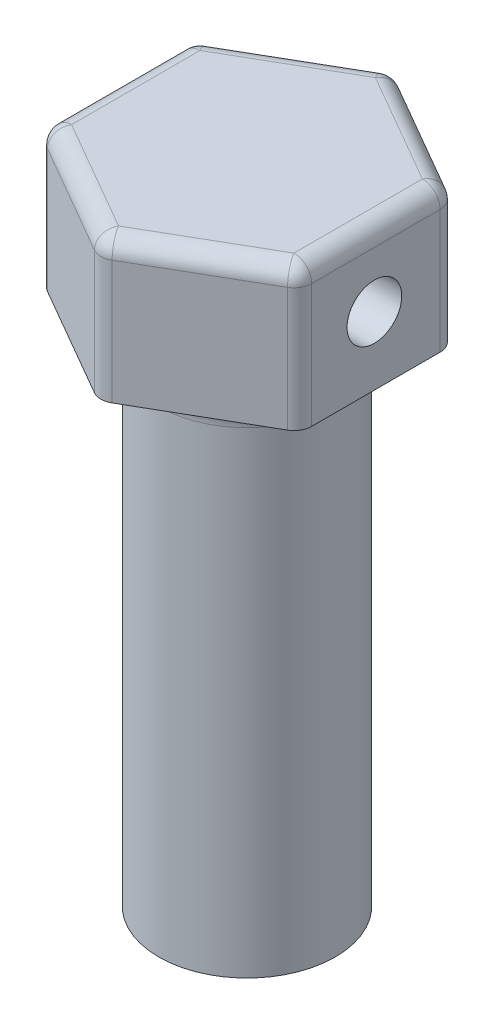
from build123d import *

# Parameters (mm, degrees)
BOSS_EXTRUDE1_DEPTH = 8
SKETCH2_R           = 5
BOSS_EXTRUDE2_DEPTH = 29
FILLET1_R           = 2
SKETCH3_R           = 1.55
CUT_EXTRUDE1_DEPTH  = 15.6
FILLET2_R           = 1
SKETCH5_R           = 2.0875
CUT_EXTRUDE3_DEPTH  = 3
CUT_EXTRUDE4_REACH  = 10
SKETCH6_R           = 1.25
SKETCH7_R           = 0.5
CUT_EXTRUDE5_DEPTH  = 0.5


with BuildPart() as part:
    # Sketch1 → Boss-Extrude1 (new body)
    with BuildSketch(Plane(origin=(0, 0, 0), x_dir=(1, 0, 0), z_dir=(0, 1, 0))):
        Polygon((7.3, -4.214656965), (7.3, 4.214656965), (0, 8.42931393), (-7.3, 4.214656965), (-7.3, -4.214656965), (0, -8.42931393), align=None)
    extrude(amount=BOSS_EXTRUDE1_DEPTH)

    # Sketch2 → Boss-Extrude2 (add)
    with BuildSketch(Plane.XZ):
        Circle(SKETCH2_R)
        with BuildLine():
            Line((-1.5, 1.451776928), (-1.5, -1.451776928))
            ThreePointArc((-1.5, -1.451776928), (2.0875, 0), (-1.5, 1.451776928))
        make_face(mode=Mode.SUBTRACT)
    extrude(amount=BOSS_EXTRUDE2_DEPTH)

    # Fillet1
    fillet1_edges = [part.edges().sort_by_distance(p)[0] for p in [
        (-5, 0, 0),
    ]]
    fillet(fillet1_edges, radius=FILLET1_R)

    # Sketch3 → Cut-Extrude1 (cut, through all)
    with BuildSketch(Plane(origin=(7.3, 0, 0), x_dir=(0, 0, -1), z_dir=(1, 0, 0))):
        with Locations((-0.085343035, 3.85)):
            Circle(SKETCH3_R)
    extrude(amount=-CUT_EXTRUDE1_DEPTH, mode=Mode.SUBTRACT)

    # Fillet2
    fillet2_edges = [part.edges().sort_by_distance(p)[0] for p in [
        (0, 4, 8.42931393),
        (-7.3, 4, 4.214656965),
        (-7.3, 4, -4.214656965),
        (0, 4, -8.42931393),
        (7.3, 4, -4.214656965),
        (7.3, 4, 4.214656965),
        (3.65, 8, -6.321985448),
        (-3.65, 8, -6.321985448),
        (-7.3, 8, 0),
        (-3.65, 8, 6.321985448),
        (3.65, 8, 6.321985448),
        (7.3, 8, 0),
    ]]
    fillet(fillet2_edges, radius=FILLET2_R)

    # Sketch5 → Cut-Extrude3 (cut)
    with BuildSketch(Plane.XZ.offset(29)):
        Circle(SKETCH5_R)
    extrude(amount=-CUT_EXTRUDE3_DEPTH, mode=Mode.SUBTRACT)

    # Sketch6 → Cut-Extrude4 (cut, up to next)
    with BuildSketch(Plane.XZ, mode=Mode.PRIVATE) as cut_extrude4_sk1:
        Circle(SKETCH6_R)
    cut_extrude4_tool1 = extrude(cut_extrude4_sk1.sketch, amount=-CUT_EXTRUDE4_REACH, mode=Mode.PRIVATE) & part.part
    add(cut_extrude4_tool1.solids().sort_by_distance((0, 0, 0))[0], mode=Mode.SUBTRACT)

    # Sketch7 → Cut-Extrude5 (cut)
    with BuildSketch(Plane(origin=(3.65, 0, -6.321985448), x_dir=(-0.866025404, 0, -0.5), z_dir=(0.5, 0, -0.866025404))):
        with Locations((0, 3.5)):
            Circle(SKETCH7_R)
    extrude(amount=-CUT_EXTRUDE5_DEPTH, mode=Mode.SUBTRACT)


solid = part.part
